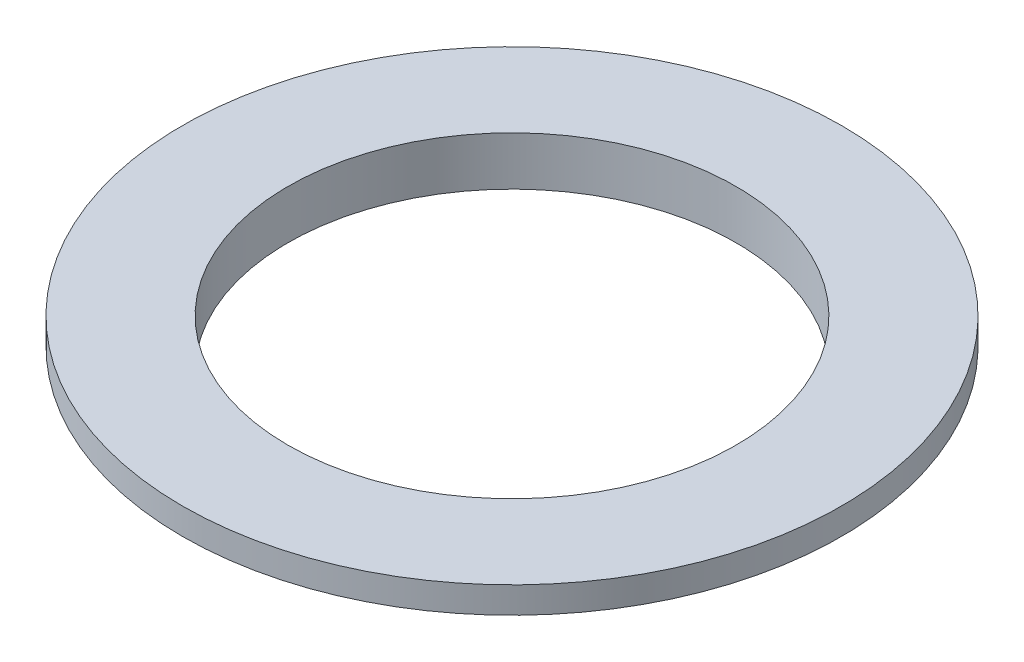
from build123d import *

# Parameters (mm, degrees)
SKETCH1_R           = 31.75
SKETCH1_R_2         = 21.59
BOSS_EXTRUDE1_DEPTH = 1.27
BOSS_EXTRUDE2_START = -1.27
SKETCH1_3_R         = 25.4
SKETCH1_3_R_2       = 21.59
BOSS_EXTRUDE2_DEPTH = 2.159


with BuildPart() as part:
    # Sketch1 → Boss-Extrude1 (new, symmetric)
    with BuildSketch(Plane(origin=(0, 0, 0), x_dir=(1, 0, 0), z_dir=(0, 1, 0))):
        with Locations(Location((0, 0, 0), (0, 0, 270))):
            Circle(SKETCH1_R)
        with Locations(Location((0, 0, 0), (0, 0, 270))):
            Circle(SKETCH1_R_2, mode=Mode.SUBTRACT)
    extrude(amount=BOSS_EXTRUDE1_DEPTH, both=True)

    # Sketch1_3 → Boss-Extrude2 (add)
    with BuildSketch(Plane(origin=(0, 0, 0), x_dir=(1, 0, 0), z_dir=(0, 1, 0)).offset(BOSS_EXTRUDE2_START)):
        with Locations(Location((0, 0, 0), (0, 0, 270))):
            Circle(SKETCH1_3_R)
        with Locations(Location((0, 0, 0), (0, 0, 270))):
            Circle(SKETCH1_3_R_2, mode=Mode.SUBTRACT)
    extrude(amount=-BOSS_EXTRUDE2_DEPTH)


solid = part.part
